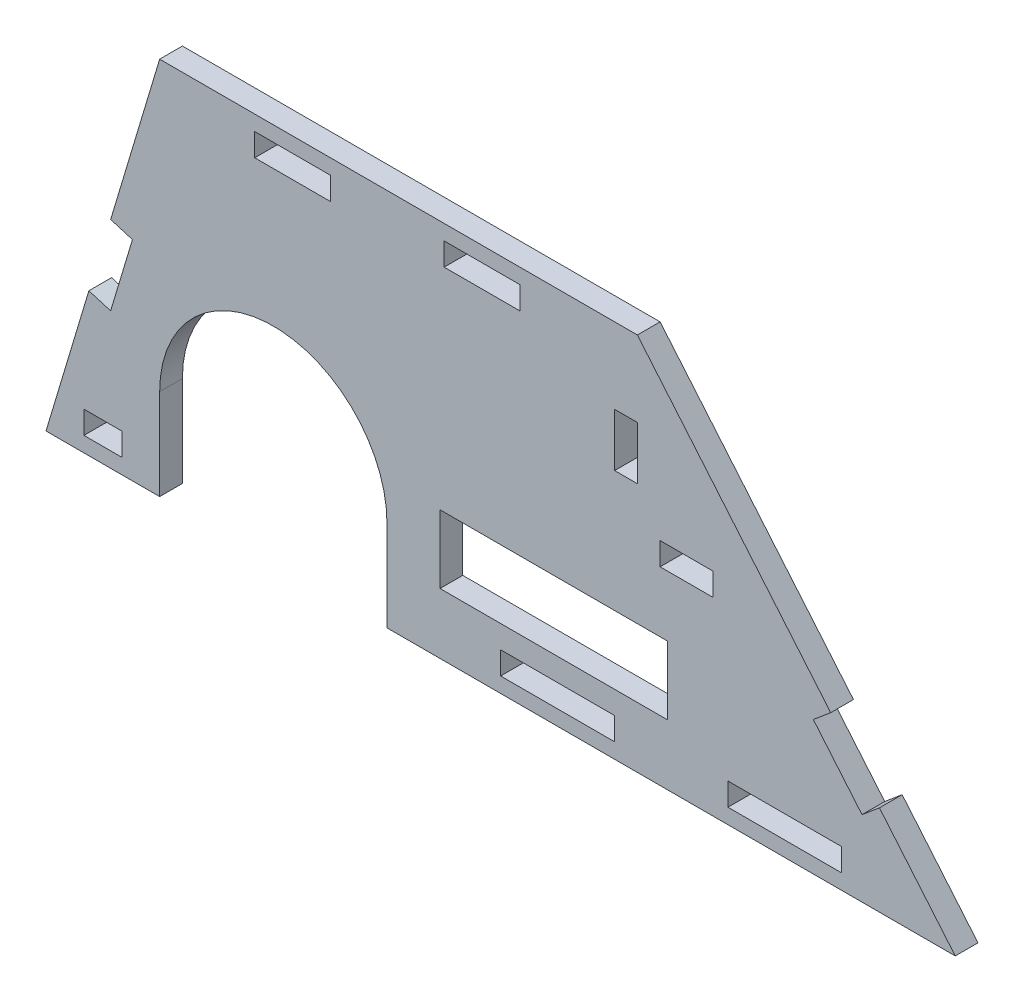
from build123d import *

# Parameters (mm, degrees)
CROQUIS1_W              = 15
CROQUIS1_H              = 3
CROQUIS1_W_2            = 5
CROQUIS1_W_3            = 30
CROQUIS1_H_2            = 9
SALIENTE_EXTRUIR1_DEPTH = 3
CROQUIS3_W              = 3
CROQUIS3_H              = 7
CROQUIS3_W_2            = 7
CROQUIS3_H_2            = 3
CORTAR_EXTRUIR2_DEPTH   = 4
CORTAR_EXTRUIR3_DEPTH   = 4
CORTAR_EXTRUIR4_DEPTH   = 4
CROQUIS7_W              = 10
CROQUIS7_H              = 3
CORTAR_EXTRUIR5_DEPTH   = 4


with BuildPart() as part:
    # Croquis1 → Saliente-Extruir1 (new body)
    with BuildSketch(Plane.XY):
        with BuildLine():
            Line((0, 0), (15, 0))
            Line((15, 0), (15, 12))
            ThreePointArc((15, 12), (30, 27), (45, 12))
            Line((45, 12), (45, 0))
            Line((45, 0), (120, 0))
            Line((120, 0), (78.045018441, 50))
            Line((78.045018441, 50), (15, 50))
            Line((15, 50), (0, 0))
        make_face()
        with Locations((97.5, 3.5)):
            Rectangle(CROQUIS1_W, CROQUIS1_H, mode=Mode.SUBTRACT)
        with Locations((67.5, 3.5)):
            Rectangle(CROQUIS1_W, CROQUIS1_H, mode=Mode.SUBTRACT)
        with Locations((7.5, 3.5)):
            Rectangle(CROQUIS1_W_2, CROQUIS1_H, mode=Mode.SUBTRACT)
        with Locations((67, 12.5)):
            Rectangle(CROQUIS1_W_3, CROQUIS1_H_2, mode=Mode.SUBTRACT)
    extrude(amount=SALIENTE_EXTRUIR1_DEPTH)

    # Croquis3 → Cortar-Extruir2 (cut, through all)
    with BuildSketch(Plane.XY.offset(3)):
        with Locations((76.545018441, 36.5)):
            Rectangle(CROQUIS3_W, CROQUIS3_H)
        with Locations((84.545018441, 26.5)):
            Rectangle(CROQUIS3_W_2, CROQUIS3_H_2)
    extrude(amount=-CORTAR_EXTRUIR2_DEPTH, mode=Mode.SUBTRACT)

    # Croquis5 → Cortar-Extruir3 (cut, through all)
    with BuildSketch(Plane.XY.offset(3)):
        Polygon((103.563039053, 19.58880726), (101.264905723, 17.660444431), (107.69278182, 10), (109.99091515, 11.928362829), align=None)
    extrude(amount=-CORTAR_EXTRUIR3_DEPTH, mode=Mode.SUBTRACT)

    # Croquis6 → Cortar-Extruir4 (cut, through all)
    with BuildSketch(Plane.XY.offset(3)):
        Polygon((8.532091953, 28.440306509), (11.405570808, 27.578262852), (8.532091953, 18), (5.658613097, 18.862043657), align=None)
    extrude(amount=-CORTAR_EXTRUIR4_DEPTH, mode=Mode.SUBTRACT)

    # Croquis7 → Cortar-Extruir5 (cut, through all)
    with BuildSketch(Plane(origin=(0, 0, 0), x_dir=(-1, 0, 0), z_dir=(0, 0, -1))):
        with Locations((-57.545018441, 46.5)):
            Rectangle(CROQUIS7_W, CROQUIS7_H)
        with Locations((-32.545018441, 46.5)):
            Rectangle(CROQUIS7_W, CROQUIS7_H)
    extrude(amount=-CORTAR_EXTRUIR5_DEPTH, mode=Mode.SUBTRACT)


solid = part.part
